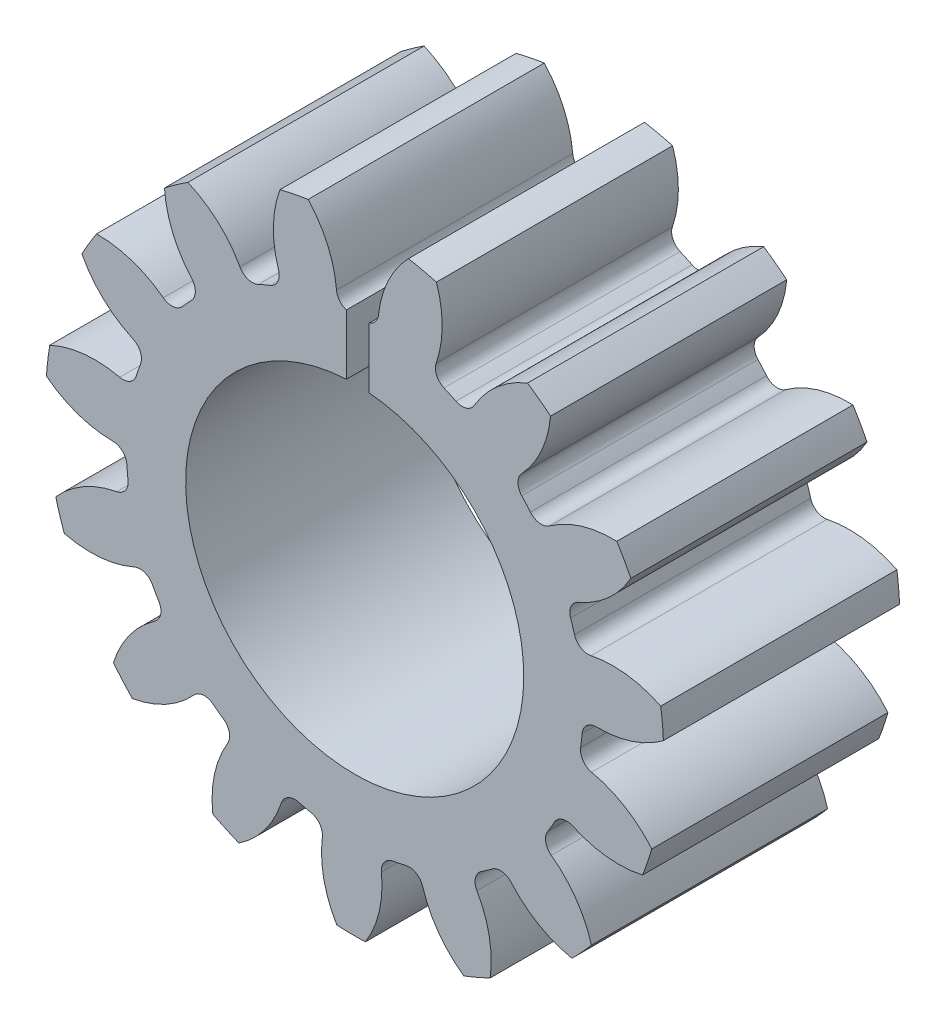
from build123d import *

# Parameters (mm, degrees)
SKETCH3_R          = 21.59
GEARBODY_DEPTH     = 11
TOOTHCUT_DEPTH     = 12
CIRPATTERN1_COUNT  = 15
SCALE1_SCALE_X     = 0.666666667
SCALE1_SCALE_Y     = 0.666666667
SCALE1_SCALE_Z     = 1
BOREDIA_R          = 7.874
BORE_DEPTH         = 12700
SKETCH5_W          = 1.060055659
SKETCH5_H          = 6.581178882
CUT_EXTRUDE1_DEPTH = 2.54


with BuildPart() as part:
    # Sketch3 → gearBody (new body)
    with BuildSketch(Plane.XY):
        Circle(SKETCH3_R)
    extrude(amount=GEARBODY_DEPTH)

    # Sketch2 → toothCut (cut, through all)
    with BuildSketch(Plane.XY):
        with BuildLine():
            ThreePointArc((16.550574786, -3.410158156), (15.949189176, -3.008551507), (15.783846764, -2.304552616))
            ThreePointArc((15.783846764, -2.304552616), (15.843293638, -1.852249483), (15.889781974, -1.39843136))
            ThreePointArc((15.889781974, -1.39843136), (16.213055843, -0.751556907), (16.890861518, -0.499501321))
            ThreePointArc((16.890861518, -0.499501321), (20.504912911, 0.340315353), (23.283949955, 2.798691365))
            ThreePointArc((23.283949955, 2.798691365), (23.292901215, -2.723187818), (22.010467945, -8.09409042))
            ThreePointArc((22.010467945, -8.09409042), (19.873444675, -5.060974685), (16.550574786, -3.410158156))
        make_face()
    toothcut = extrude(amount=TOOTHCUT_DEPTH, mode=Mode.SUBTRACT)

    # CirPattern1: toothCut ×15 about axis
    cirpattern1_axis = Axis((0, 0, 0), (0, 0, 1))
    for i in range(1, CIRPATTERN1_COUNT):
        add(toothcut.rotate(cirpattern1_axis, i * 360 / CIRPATTERN1_COUNT), mode=Mode.SUBTRACT)


with BuildPart() as part_1:
    # Scale1: scaled about (0, 0, 5.5)
    add(part.part.scale((SCALE1_SCALE_X, SCALE1_SCALE_Y, SCALE1_SCALE_Z), about=(0, 0, 5.5)))

    # boreDia → bore (cut, symmetric)
    with BuildSketch(Plane.XY):
        Circle(BOREDIA_R)
    extrude(amount=BORE_DEPTH, both=True, mode=Mode.SUBTRACT)

    # Sketch5 → Cut-Extrude1 (cut)
    with BuildSketch(Plane.XY.offset(11)):
        with Locations((0.142274151, 9.712282743)):
            Rectangle(SKETCH5_W, SKETCH5_H)
    extrude(amount=-CUT_EXTRUDE1_DEPTH, mode=Mode.SUBTRACT)


solid = part_1.part
